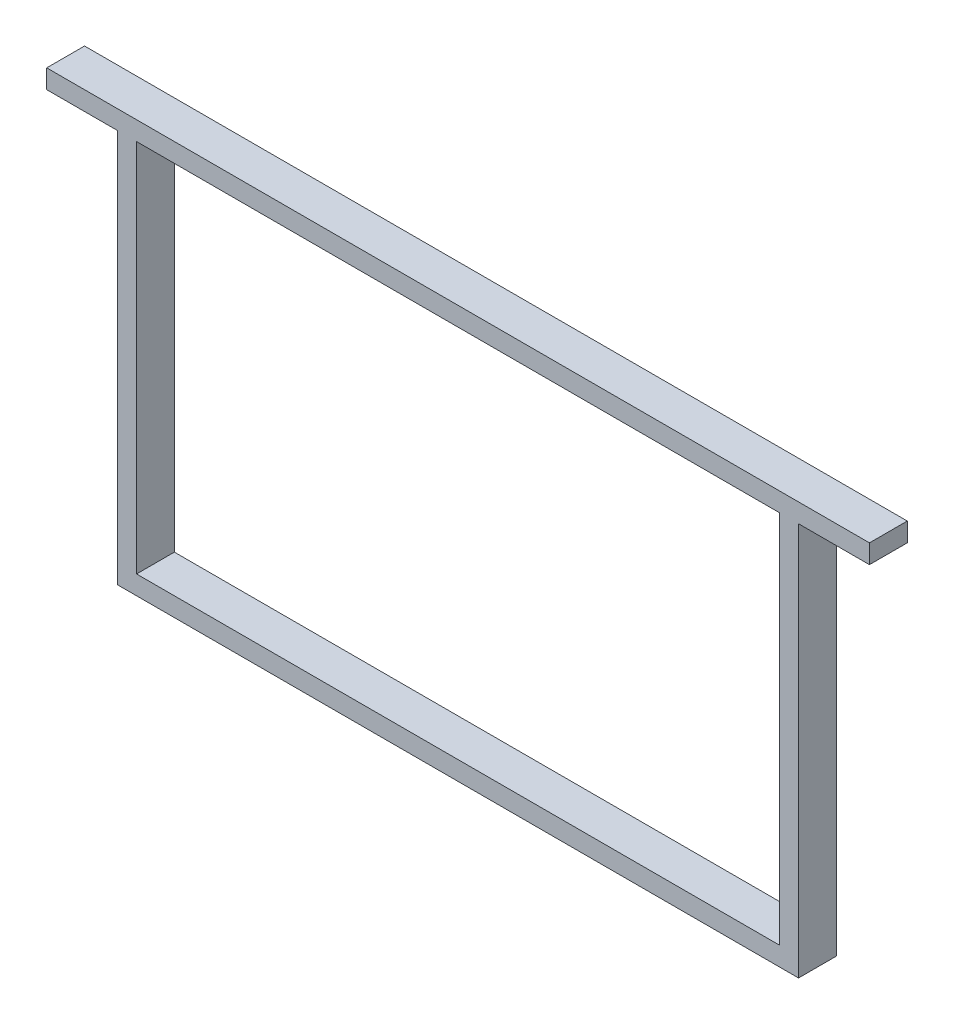
from build123d import *

# Parameters (mm, degrees)
SKETCH1_W           = 360
SKETCH1_H           = 218
SKETCH1_W_2         = 340
SKETCH1_H_2         = 198
SKETCH1_W_3         = 37.5
SKETCH1_H_3         = 10
BOSS_EXTRUDE1_DEPTH = 20


with BuildPart() as part:
    # Sketch1 → Boss-Extrude1 (new body)
    with BuildSketch(Plane.XY):
        Rectangle(SKETCH1_W, SKETCH1_H)
        Rectangle(SKETCH1_W_2, SKETCH1_H_2, mode=Mode.SUBTRACT)
        with Locations((-198.75, 104)):
            Rectangle(SKETCH1_W_3, SKETCH1_H_3)
        with Locations((198.75, 104)):
            Rectangle(SKETCH1_W_3, SKETCH1_H_3)
    extrude(amount=BOSS_EXTRUDE1_DEPTH)


solid = part.part
